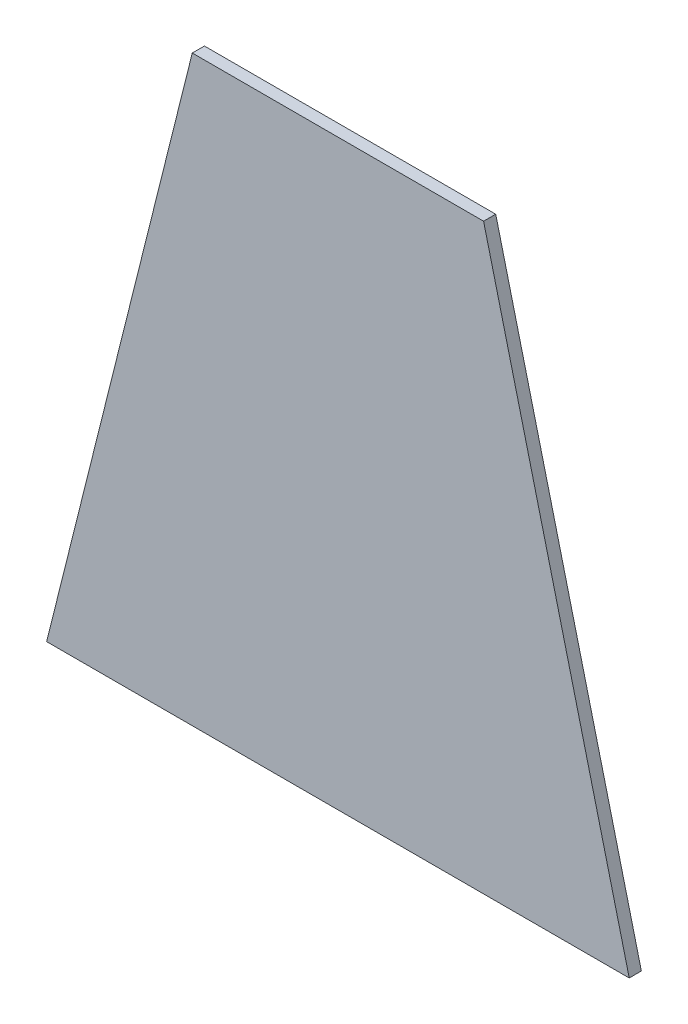
from build123d import *

# Parameters (mm, degrees)
BOSS_EXTRUDE1_DEPTH = 3.175


with BuildPart() as part:
    # Sketch2 → Boss-Extrude1 (new body)
    with BuildSketch(Plane.XY):
        Polygon((0, 0), (152.4, 0), (114.3, 152.4), (38.1, 152.4), align=None)
    extrude(amount=BOSS_EXTRUDE1_DEPTH)


solid = part.part
